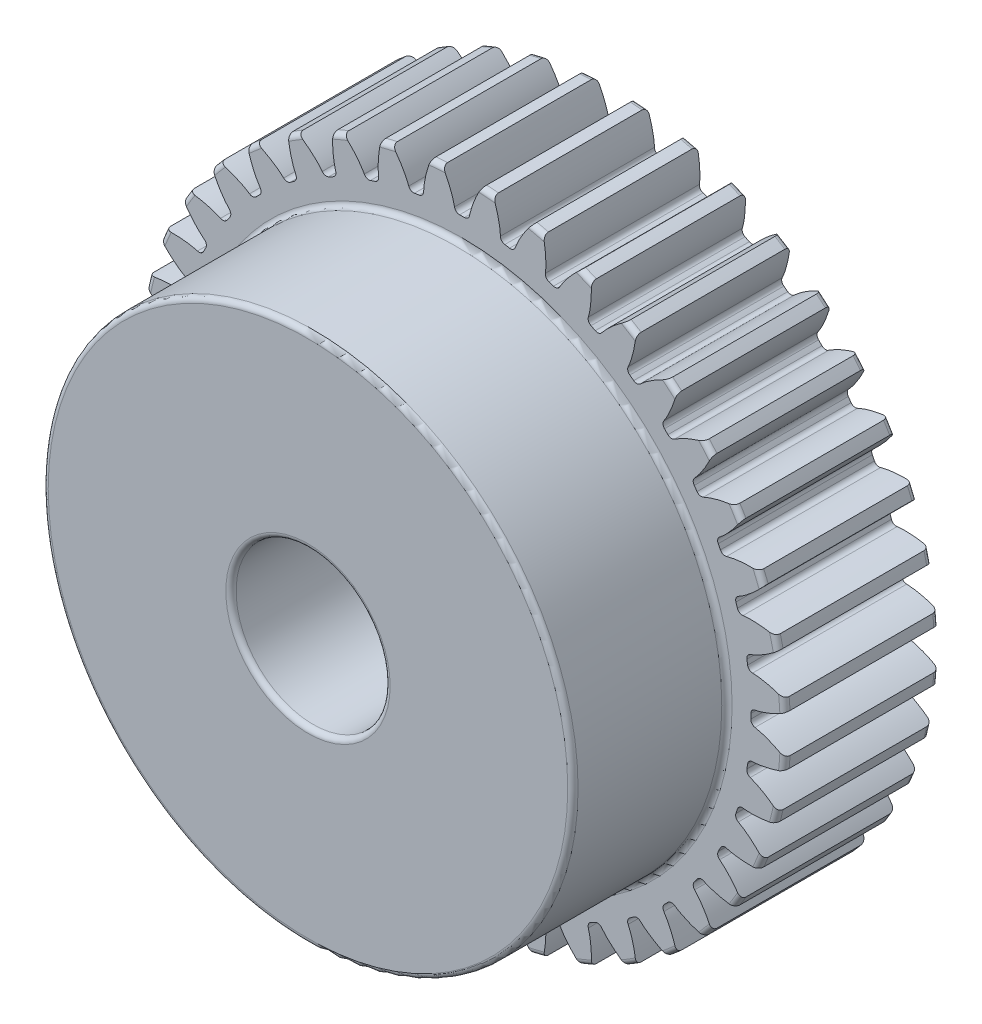
from build123d import *

# Parameters (mm, degrees)
SKETCH3_R                = 26.67
BOSS_EXTRUDE1_DEPTH      = 12.7
BOSS_EXTRUDE1_DEPTH_BACK = 12.7
SKETCH5_W                = 12.7
SKETCH5_H                = 4.826
SKETCH5_W_2              = 25.4
SKETCH5_H_2              = 6.35
FILLET2_R                = 0.426091396
CUT_EXTRUDE1_START       = -13.7
CUT_EXTRUDE1_DEPTH       = 27.4000001
FILLET1_R                = 0.426091396
CIRPATTERN1_COUNT        = 40
FILLET1_OF_CIRPATTERN1_R = 0.426091396


with BuildPart() as part:
    # Sketch3 → Boss-Extrude1 (new body, two sides)
    with BuildSketch(Plane.XY) as boss_extrude1_sk:
        Circle(SKETCH3_R)
    extrude(amount=BOSS_EXTRUDE1_DEPTH)
    extrude(boss_extrude1_sk.sketch, amount=-BOSS_EXTRUDE1_DEPTH_BACK)

    # Sketch5 → Cut-Revolve1 (revolve, cut)
    with BuildSketch(Plane(origin=(0, 0, 0), x_dir=(0, 0, -1), z_dir=(1, 0, 0))):
        with Locations((-6.35, 24.257)):
            Rectangle(SKETCH5_W, SKETCH5_H)
        with Locations((0, 3.175)):
            Rectangle(SKETCH5_W_2, SKETCH5_H_2)
    revolve(axis=Axis((0, 0, 12.7), (0, 0, -1)), mode=Mode.SUBTRACT)

    # Fillet2
    fillet2_edges = [part.edges().sort_by_distance(p)[0] for p in [
        (0, -6.35, 12.7),
        (0, -6.35, -12.7),
        (0, -21.844, 12.7),
        (0, -21.844, 0),
        (-26.67, 0, 0),
        (-26.67, 0, -12.7),
    ]]
    fillet(fillet2_edges, radius=FILLET2_R)

    # Sketch4 → Cut-Extrude1 (cut)
    with BuildSketch(Plane.XY.offset(CUT_EXTRUDE1_START)):
        with BuildLine():
            Line((23.805431862, 0.58014664), (23.861107899, 0.581503484))
            add(Edge.make_bspline(
                [(23.861107899, 0.581503484), (23.865491394, 0.581656584), (23.877782006, 0.582229225), (23.901001525, 0.583877498), (23.938862615, 0.587370548), (23.98705952, 0.593002454), (24.049296811, 0.601638249), (24.122530739, 0.613556165), (24.202917072, 0.628481684), (24.290260257, 0.646693102), (24.377288642, 0.666606389), (24.463993984, 0.688094976), (24.550261373, 0.710965729), (24.65462588, 0.740400625), (24.779577858, 0.778101916), (24.925325839, 0.825674511), (25.090251782, 0.88376555), (25.257910771, 0.947393641), (25.422524397, 1.013638057), (25.588399373, 1.084747707), (25.748575087, 1.156510249), (25.914462046, 1.235329419), (26.067337555, 1.310259595), (26.238045397, 1.398944077), (26.375644023, 1.471895525), (26.51728997, 1.551202577), (26.586156499, 1.590384455), (26.621320267, 1.610654285)],
                knots=[0, 0, 0, 0, 0, 0.005376749, 0.015083688, 0.02853182, 0.04661014, 0.064854849, 0.092110526, 0.119476176, 0.146842496, 0.174208854, 0.201574956, 0.228941013, 0.256307345, 0.307035032, 0.361767352, 0.416499661, 0.471231937, 0.525964282, 0.580696616, 0.635428982, 0.690161387, 0.744893688, 0.799626082, 0.854358407, 0.909090914, 0.909090914, 0.909090914, 0.909090914, 0.909090914], degree=4))
            ThreePointArc((26.621320267, 1.610654285), (26.67, 0), (26.621320267, -1.610654285))
            add(Edge.make_bspline(
                [(23.861107899, -0.581503484), (23.865491394, -0.581656584), (23.877782006, -0.582229225), (23.901001525, -0.583877498), (23.938862615, -0.587370548), (23.98705952, -0.593002454), (24.049296811, -0.601638249), (24.122530739, -0.613556165), (24.202917072, -0.628481684), (24.290260257, -0.646693102), (24.377288642, -0.666606389), (24.463993984, -0.688094976), (24.550261373, -0.710965729), (24.65462588, -0.740400625), (24.779577858, -0.778101916), (24.925325839, -0.825674511), (25.090251782, -0.88376555), (25.257910771, -0.947393641), (25.422524397, -1.013638057), (25.588399373, -1.084747707), (25.748575087, -1.156510249), (25.914462046, -1.235329419), (26.067337555, -1.310259595), (26.238045397, -1.398944077), (26.375644023, -1.471895525), (26.51728997, -1.551202577), (26.586156499, -1.590384455), (26.621320267, -1.610654285)],
                knots=[0, 0, 0, 0, 0, 0.005376749, 0.015083688, 0.02853182, 0.04661014, 0.064854849, 0.092110526, 0.119476176, 0.146842496, 0.174208854, 0.201574956, 0.228941013, 0.256307345, 0.307035032, 0.361767352, 0.416499661, 0.471231937, 0.525964282, 0.580696616, 0.635428982, 0.690161387, 0.744893688, 0.799626082, 0.854358407, 0.909090914, 0.909090914, 0.909090914, 0.909090914, 0.909090914], degree=4))
            Line((23.861107899, -0.581503484), (23.805431862, -0.58014664))
            ThreePointArc((23.805431862, -0.58014664), (23.8125, 0), (23.805431862, 0.58014664))
        make_face()
    cut_extrude1 = extrude(amount=CUT_EXTRUDE1_DEPTH, mode=Mode.SUBTRACT)

    # Fillet1
    fillet1_edges = [part.edges().sort_by_distance(p)[0] for p in [
        (23.805431862, -0.58014664, -6.35),
        (23.805431862, 0.58014664, -6.35),
    ]]
    fillet(fillet1_edges, radius=FILLET1_R)

    # CirPattern1: Cut-Extrude1 ×40 about axis
    cirpattern1_axis = Axis((0, 0, 12.7), (0, 0, -1))
    for i in range(1, CIRPATTERN1_COUNT):
        add(cut_extrude1.rotate(cirpattern1_axis, i * 360 / CIRPATTERN1_COUNT), mode=Mode.SUBTRACT)

    # Fillet1 of CirPattern1
    fillet1_of_cirpattern1_edges = [part.edges().sort_by_distance(p)[0] for p in [
        (23.421592563, -4.296994071, -6.35),
        (23.603102422, -3.150985926, -6.35),
        (22.461035924, -7.908035246, -6.35),
        (22.819586266, -6.804530761, -6.35),
        (20.947414037, -11.324354349, -6.35),
        (21.474176163, -10.290525466, -6.35),
        (18.917997295, -14.461830264, -6.35),
        (19.600000574, -13.523133282, -6.35),
        (16.422756675, -17.243207922, -6.35),
        (17.243207922, -16.422756675, -6.35),
        (13.523133282, -19.600000574, -6.35),
        (14.461830264, -18.917997295, -6.35),
        (10.290525466, -21.474176163, -6.35),
        (11.324354349, -20.947414037, -6.35),
        (6.804530761, -22.819586266, -6.35),
        (7.908035246, -22.461035924, -6.35),
        (3.150985926, -23.603102422, -6.35),
        (4.296994071, -23.421592563, -6.35),
        (-0.58014664, -23.805431862, -6.35),
        (0.58014664, -23.805431862, -6.35),
        (-4.296994071, -23.421592563, -6.35),
        (-3.150985926, -23.603102422, -6.35),
        (-7.908035246, -22.461035924, -6.35),
        (-6.804530761, -22.819586266, -6.35),
        (-11.324354349, -20.947414037, -6.35),
        (-10.290525466, -21.474176163, -6.35),
        (-14.461830264, -18.917997295, -6.35),
        (-13.523133282, -19.600000574, -6.35),
        (-17.243207922, -16.422756675, -6.35),
        (-16.422756675, -17.243207922, -6.35),
        (-19.600000574, -13.523133282, -6.35),
        (-18.917997295, -14.461830264, -6.35),
        (-21.474176163, -10.290525466, -6.35),
        (-20.947414037, -11.324354349, -6.35),
        (-22.819586266, -6.804530761, -6.35),
        (-22.461035924, -7.908035246, -6.35),
        (-23.603102422, -3.150985926, -6.35),
        (-23.421592563, -4.296994071, -6.35),
        (-23.805431862, 0.58014664, -6.35),
        (-23.805431862, -0.58014664, -6.35),
        (-23.421592563, 4.296994071, -6.35),
        (-23.603102422, 3.150985926, -6.35),
        (-22.461035924, 7.908035246, -6.35),
        (-22.819586266, 6.804530761, -6.35),
        (-20.947414037, 11.324354349, -6.35),
        (-21.474176163, 10.290525466, -6.35),
        (-18.917997295, 14.461830264, -6.35),
        (-19.600000574, 13.523133282, -6.35),
        (-16.422756675, 17.243207922, -6.35),
        (-17.243207922, 16.422756675, -6.35),
        (-13.523133282, 19.600000574, -6.35),
        (-14.461830264, 18.917997295, -6.35),
        (-10.290525466, 21.474176163, -6.35),
        (-11.324354349, 20.947414037, -6.35),
        (-6.804530761, 22.819586266, -6.35),
        (-7.908035246, 22.461035924, -6.35),
        (-3.150985926, 23.603102422, -6.35),
        (-4.296994071, 23.421592563, -6.35),
        (0.58014664, 23.805431862, -6.35),
        (-0.58014664, 23.805431862, -6.35),
        (4.296994071, 23.421592563, -6.35),
        (3.150985926, 23.603102422, -6.35),
        (7.908035246, 22.461035924, -6.35),
        (6.804530761, 22.819586266, -6.35),
        (11.324354349, 20.947414037, -6.35),
        (10.290525466, 21.474176163, -6.35),
        (14.461830264, 18.917997295, -6.35),
        (13.523133282, 19.600000574, -6.35),
        (17.243207922, 16.422756675, -6.35),
        (16.422756675, 17.243207922, -6.35),
        (19.600000574, 13.523133282, -6.35),
        (18.917997295, 14.461830264, -6.35),
        (21.474176163, 10.290525466, -6.35),
        (20.947414037, 11.324354349, -6.35),
        (22.819586266, 6.804530761, -6.35),
        (22.461035924, 7.908035246, -6.35),
        (23.603102422, 3.150985926, -6.35),
        (23.421592563, 4.296994071, -6.35),
    ]]
    fillet(fillet1_of_cirpattern1_edges, radius=FILLET1_OF_CIRPATTERN1_R)


solid = part.part
